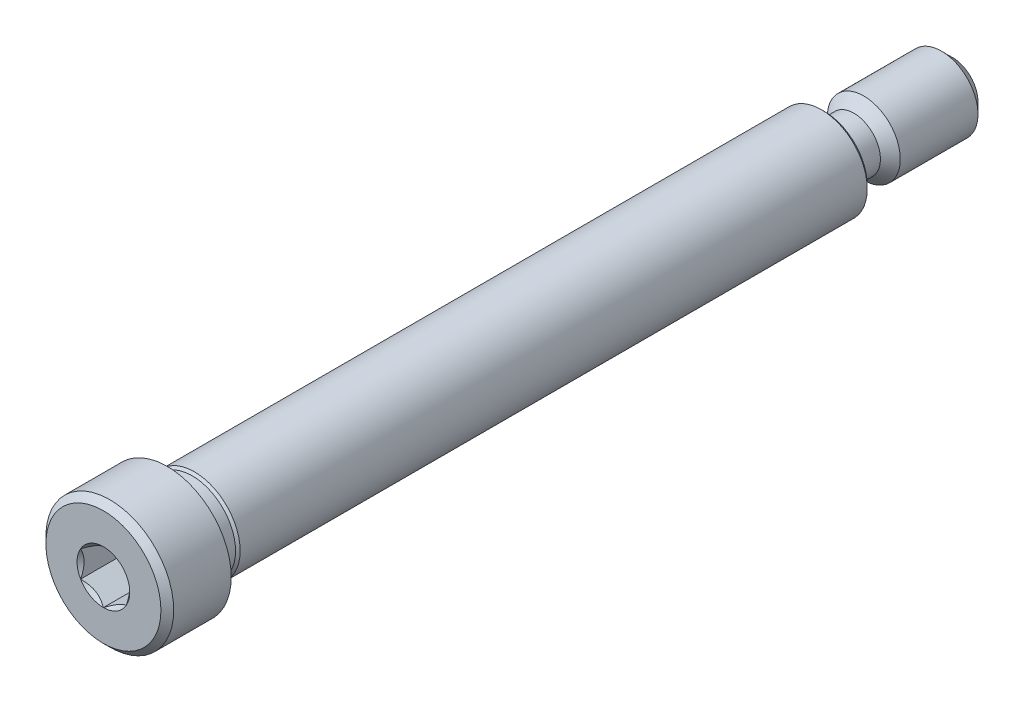
from build123d import *

# Parameters (mm, degrees)
CUT_EXTRUDE1_DEPTH = 4.1671875


with BuildPart() as part:
    # Sketch4 → Revolve1 (revolve)
    with BuildSketch(Plane(origin=(0, 0, 0), x_dir=(0, 0, -1), z_dir=(1, 0, 0))):
        Polygon((-31.353125, 5.55625), (-36.35375, 5.55625), (-36.909375, 5.000625), (-36.909375, 0), (25.796875, 0), (25.796875, 3.704166667), (25.532291667, 3.96875), (-28.990925, 3.96875), (-29.1893625, 3.7703125), (-31.1546875, 3.7703125), (-31.353125, 3.96875), align=None)
    revolve(axis=Axis((0, 0, 36.909375), (0, 0, -1)))

    # Sketch5 → Cut-Extrude1 (cut)
    with BuildSketch(Plane.XY.offset(36.909375)):
        Polygon((1.984375, 1.14567944), (0, 2.291358881), (-1.984375, 1.14567944), (-1.984375, -1.14567944), (0, -2.291358881), (1.984375, -1.14567944), align=None)
    extrude(amount=-CUT_EXTRUDE1_DEPTH, mode=Mode.SUBTRACT)

    # Cut-Extrude4 cone 1 section (through the dimple's axis) → Cut-Extrude4 (revolve, cut)
    with BuildSketch(Plane(origin=(0, 0, 36.909375), x_dir=(0, -1, 0), z_dir=(1, 0, 0))):
        Polygon((0, 0), (2.291358881, 0), (0, 2.291358881), align=None)
    revolve(axis=Axis((0, 0, 36.909375), (0, 0, -1)), mode=Mode.SUBTRACT)

    # Sketch7 → Revolve2 (revolve)
    with BuildSketch(Plane(origin=(0, 0, 0), x_dir=(0, 0, -1), z_dir=(1, 0, 0))):
        Polygon((25.796875, 3.175), (35.956875, 3.175), (36.909375, 2.2225), (36.909375, 0), (25.796875, 0), align=None)
    revolve(axis=Axis((0, 0, -36.909375), (0, 0, 1)))

    # Sketch10 → Cut-Revolve1 (revolve, cut)
    with BuildSketch(Plane(origin=(0, 0, 0), x_dir=(0, 0, -1), z_dir=(1, 0, 0))):
        with BuildLine():
            Line((26.660475, 2.3114), (28.336875, 2.3114))
            Line((28.336875, 2.3114), (29.994225, 3.96875))
            Line((29.994225, 3.96875), (25.796875, 3.96875))
            Line((25.796875, 3.96875), (25.796875, 3.175))
            ThreePointArc((25.796875, 3.175), (26.049817584, 2.564342584), (26.660475, 2.3114))
        make_face()
    revolve(axis=Axis((0, 0, -36.909375), (0, 0, 1)), mode=Mode.SUBTRACT)


solid = part.part
